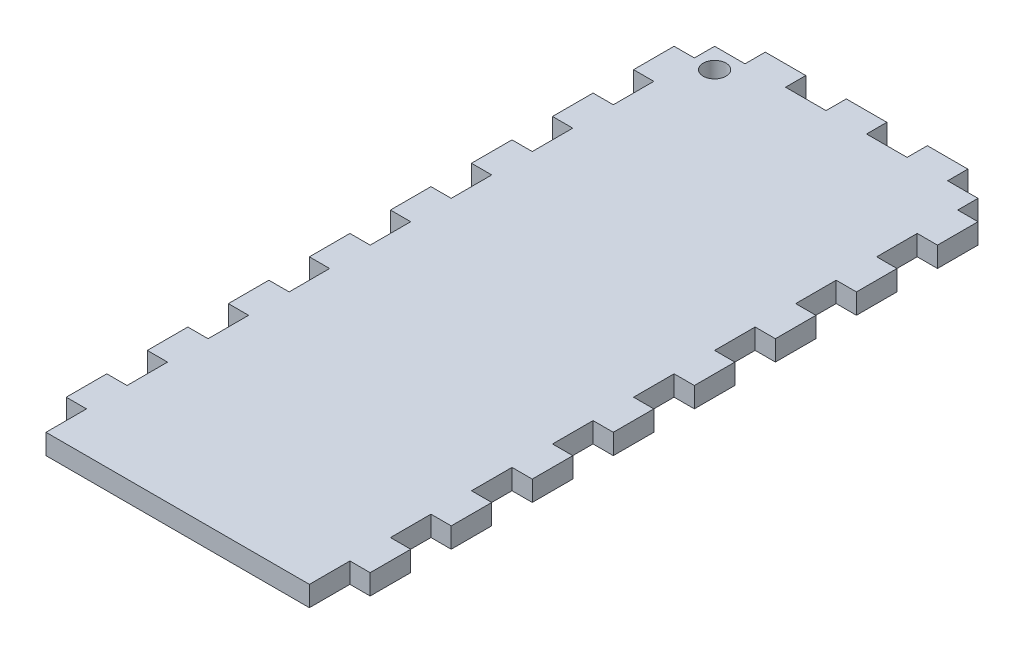
from build123d import *

# Parameters (mm, degrees)
SKETCH1_W           = 95.25
SKETCH1_H           = 215.9
BOSS_EXTRUDE1_DEPTH = 6.35
SKETCH2_W           = 6.35
SKETCH2_H           = 12.7
CUT_EXTRUDE1_DEPTH  = 7.35
LPATTERN1_COUNT     = 10
LPATTERN1_PITCH     = 25.4
SKETCH3_W           = 12.7
SKETCH3_H           = 6.35
CUT_EXTRUDE2_DEPTH  = 7.35
LPATTERN2_COUNT     = 2
LPATTERN2_PITCH     = 25.4
LPATTERN2_COL_COUNT = 3
LPATTERN2_COL_PITCH = 25.4
SKETCH4_R           = 3.571875
CUT_EXTRUDE3_DEPTH  = 7.35


with BuildPart() as part:
    # Sketch1 → Boss-Extrude1 (new body)
    with BuildSketch(Plane(origin=(0, 0, 0), x_dir=(1, 0, 0), z_dir=(0, 1, 0))):
        with Locations((47.625, 107.95)):
            Rectangle(SKETCH1_W, SKETCH1_H)
    extrude(amount=BOSS_EXTRUDE1_DEPTH)

    # Sketch2 → Cut-Extrude1 (cut, through all)
    with BuildSketch(Plane(origin=(0, 6.35, 0), x_dir=(1, 0, 0), z_dir=(0, 1, 0))):
        with Locations((3.175, 209.55)):
            Rectangle(SKETCH2_W, SKETCH2_H)
        with Locations((92.075, 209.55)):
            Rectangle(SKETCH2_W, SKETCH2_H)
    cut_extrude1 = extrude(amount=-CUT_EXTRUDE1_DEPTH, mode=Mode.SUBTRACT)

    # LPattern1: Cut-Extrude1 ×10
    with Locations(*[(0, 0, i * LPATTERN1_PITCH) for i in range(1, LPATTERN1_COUNT)]):
        add(cut_extrude1, mode=Mode.SUBTRACT)

    # Sketch3 → Cut-Extrude2 (cut, through all)
    with BuildSketch(Plane(origin=(0, 6.35, 0), x_dir=(1, 0, 0), z_dir=(0, 1, 0))):
        with Locations((34.925, 212.725)):
            Rectangle(SKETCH3_W, SKETCH3_H)
    cut_extrude2 = extrude(amount=-CUT_EXTRUDE2_DEPTH, mode=Mode.SUBTRACT)

    # LPattern2: Cut-Extrude2 ×2
    with Locations(*[(-i * LPATTERN2_PITCH, 0, 0) for i in range(1, LPATTERN2_COUNT)]):
        add(cut_extrude2, mode=Mode.SUBTRACT)

    # LPattern2 col: Cut-Extrude2 ×3
    with Locations(*[(i * LPATTERN2_COL_PITCH, 0, 0) for i in range(1, LPATTERN2_COL_COUNT)]):
        add(cut_extrude2, mode=Mode.SUBTRACT)

    # Sketch4 → Cut-Extrude3 (cut, through all)
    with BuildSketch(Plane(origin=(0, 6.35, 0), x_dir=(1, 0, 0), z_dir=(0, 1, 0))):
        with Locations((12.7, 203.2)):
            Circle(SKETCH4_R)
    extrude(amount=-CUT_EXTRUDE3_DEPTH, mode=Mode.SUBTRACT)


solid = part.part
